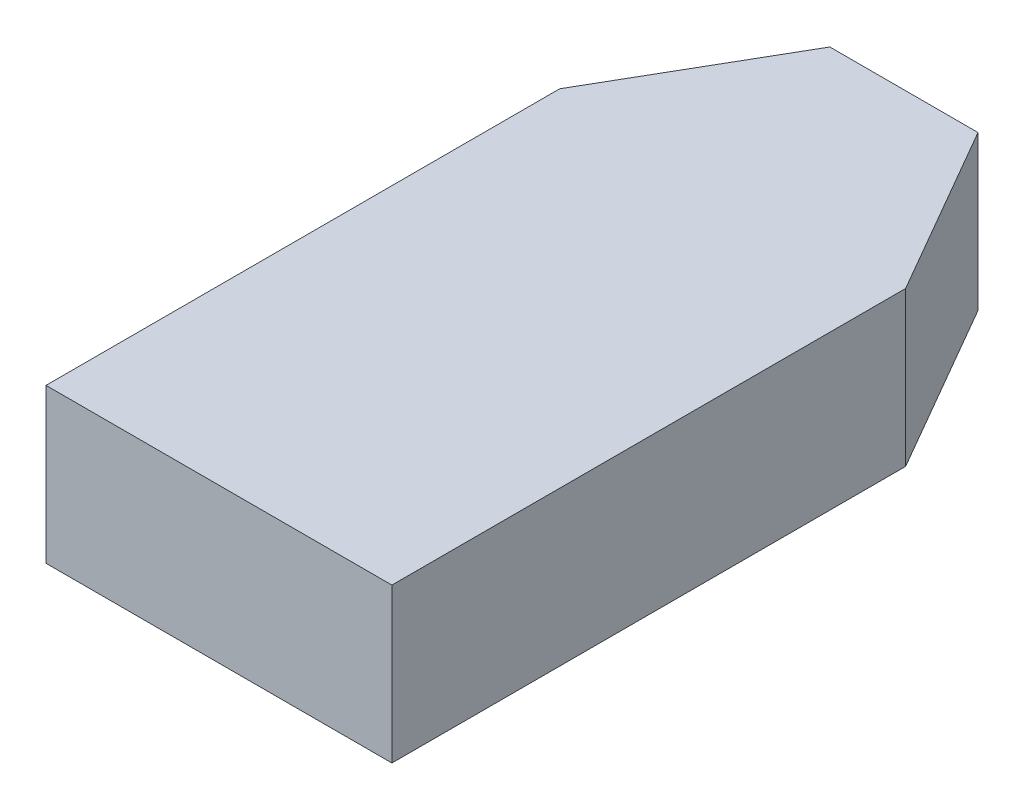
from build123d import *

# Parameters (mm, degrees)
EXTRUDE_1_DEPTH = 9


with BuildPart() as part:
    # Эскиз1 → Бобышка-Вытянуть1 (new body)
    with BuildSketch(Plane(origin=(0, 0, 0), x_dir=(1, 0, 0), z_dir=(0, 1, 0))):
        Polygon((0, 30), (0, 0), (20.2, 0), (20.2, 30), (14.426497308, 40), (5.773502692, 40), align=None)
    extrude(amount=EXTRUDE_1_DEPTH)


solid = part.part
